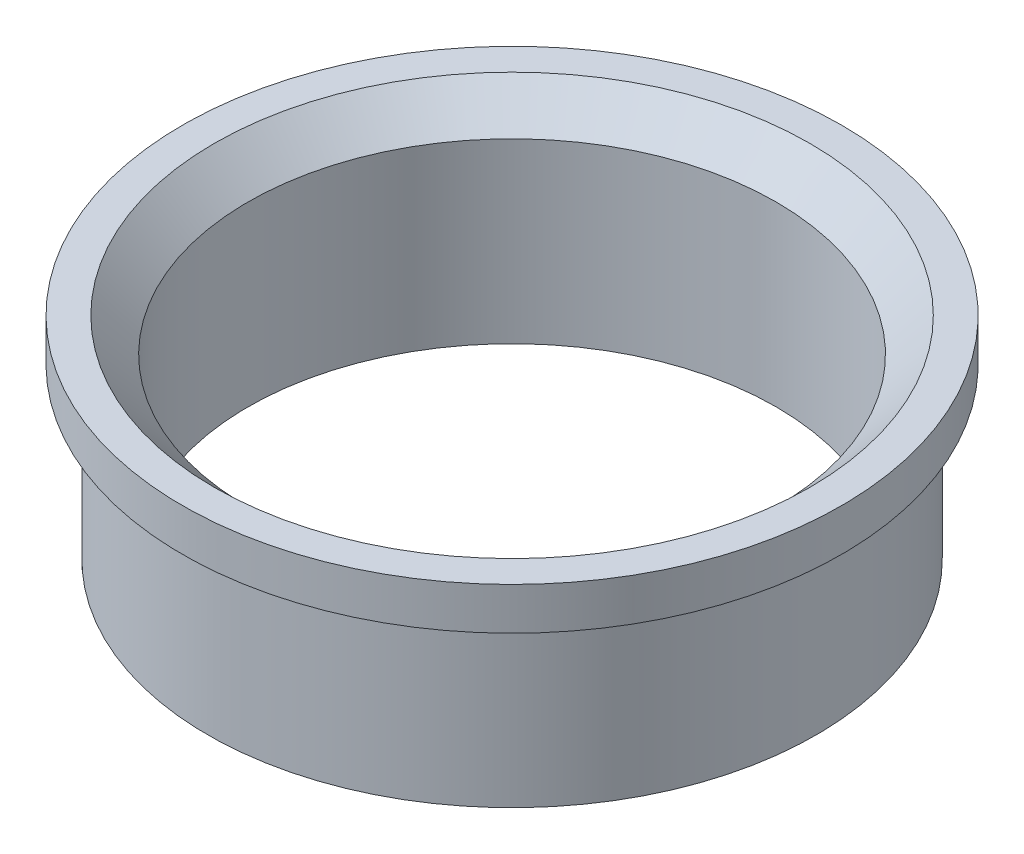
from build123d import *


with BuildPart() as part:
    # Sketch1 → Revolve1 (revolve)
    with BuildSketch(Plane.XY):
        Polygon((62.5, 0), (62.5, 42), (70.5, 50), (78, 50), (78, 40), (72, 40), (72, 0), align=None)
    revolve(axis=Axis((0, 0, 0), (0, 1, 0)))


solid = part.part
